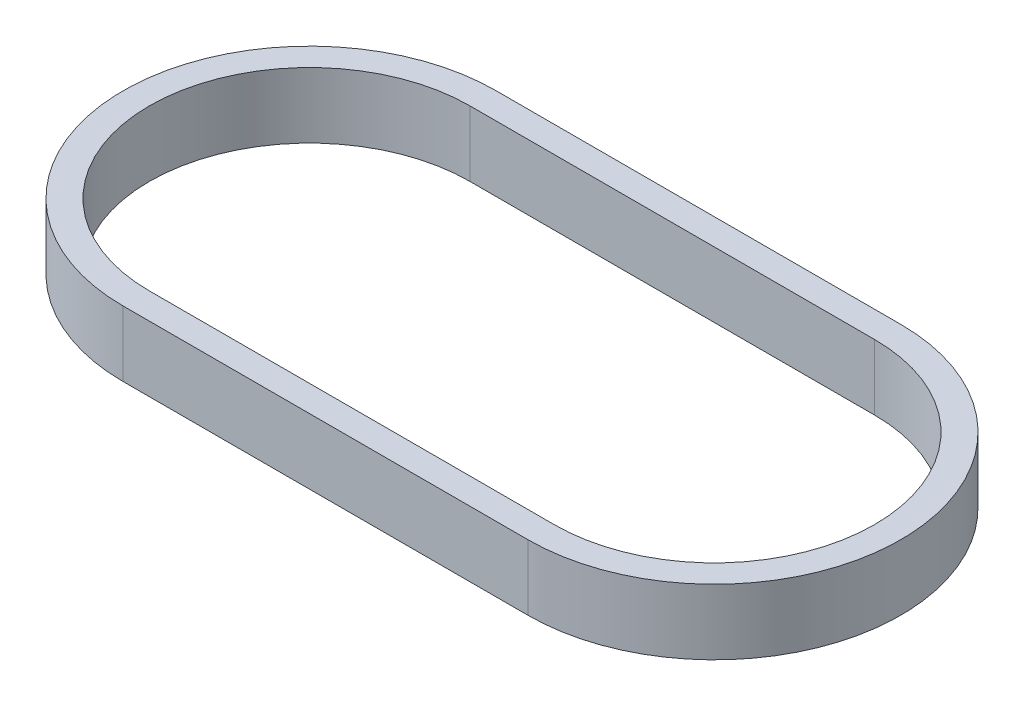
from build123d import *

# Parameters (mm, degrees)
BOSS_EXTRUDE1_DEPTH = 12.7


with BuildPart() as part:
    # Sketch1 → Boss-Extrude1 (new body)
    with BuildSketch(Plane(origin=(0, 0, 0), x_dir=(1, 0, 0), z_dir=(0, 1, 0))):
        with BuildLine():
            Line((0, 36.172140165), (78.520748037, 36.172140165))
            ThreePointArc((78.520748037, 36.172140165), (114.692888203, 0), (78.520748037, -36.172140165))
            Line((78.520748037, -36.172140165), (0, -36.172140165))
            ThreePointArc((0, -36.172140165), (-36.172140165, 0), (0, 36.172140165))
        make_face()
        with BuildLine():
            Line((0, 31.092140165), (78.520748037, 31.092140165))
            ThreePointArc((78.520748037, 31.092140165), (109.612888203, 0), (78.520748037, -31.092140165))
            Line((78.520748037, -31.092140165), (0, -31.092140165))
            ThreePointArc((0, -31.092140165), (-31.092140165, 0), (0, 31.092140165))
        make_face(mode=Mode.SUBTRACT)
    extrude(amount=BOSS_EXTRUDE1_DEPTH)


solid = part.part
